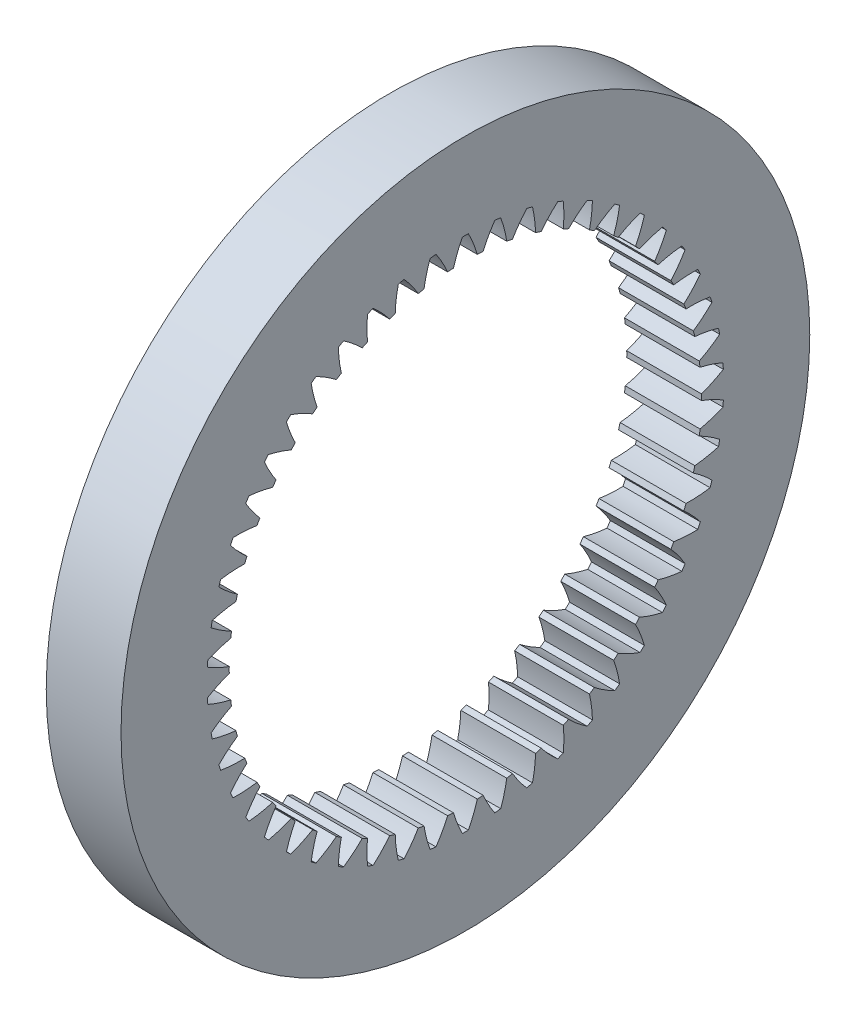
from build123d import *

# Parameters (mm, degrees)
BASPROSKE_W     = 15.2
BASPROSKE_H     = 22
TOOTHCUT_DEPTH  = 101.155079751
TEETHCUTS_COUNT = 50
TEETHCUTS_ANGLE = 352.8


with BuildPart() as part:
    # BasProSke → Base-Revolve (revolve)
    with BuildSketch(Plane(origin=(0, 0, 0), x_dir=(1, 0, 0), z_dir=(0, 1, 0))):
        with Locations((7.6, 59)):
            Rectangle(BASPROSKE_W, BASPROSKE_H)
    revolve(axis=Axis((-10, 0, 0), (1, 0, 0)))

    # TooCutSke → ToothCut (cut, through all)
    with BuildSketch(Plane(origin=(0, 0, 0), x_dir=(0, 0, -1), z_dir=(1, 0, 0))):
        with BuildLine():
            ThreePointArc((2.426707814, 47.913185391), (1.628356337, 50.250450788), (0.603274723, 52.497533853))
            ThreePointArc((0.603274723, 52.497533853), (0, 52.501), (-0.603274723, 52.497533853))
            ThreePointArc((-0.603274723, 52.497533853), (-1.628356337, 50.250450788), (-2.426707814, 47.913185391))
            ThreePointArc((-2.426707814, 47.913185391), (0, 47.9746), (2.426707814, 47.913185391))
        make_face()
    toothcut = extrude(amount=TOOTHCUT_DEPTH, mode=Mode.SUBTRACT)

    # TeethCuts: ToothCut ×50 about axis
    teethcuts_axis = Axis((-10, 0, 0), (1, 0, 0))
    for i in range(1, TEETHCUTS_COUNT):
        add(toothcut.rotate(teethcuts_axis, i * TEETHCUTS_ANGLE / (TEETHCUTS_COUNT - 1)), mode=Mode.SUBTRACT)


solid = part.part
